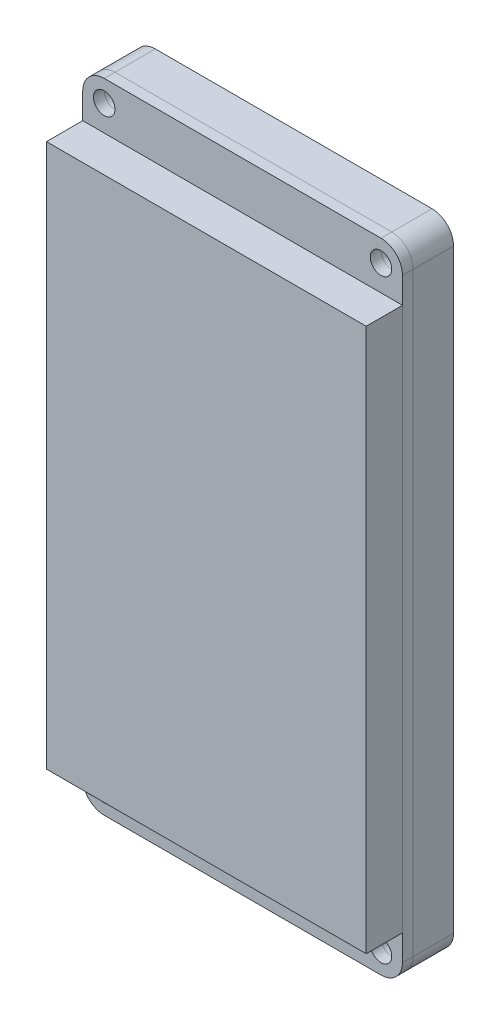
from build123d import *

# Parameters (mm, degrees)
SKETCH1_R           = 1.6
BOSS_EXTRUDE1_DEPTH = 1.6
SKETCH2_W           = 47.6
SKETCH2_H           = 80.9
BOSS_EXTRUDE2_DEPTH = 5.4
SKETCH1_2_R         = 1.6
BOSS_EXTRUDE3_DEPTH = 6
SKETCH3_W           = 15.12
SKETCH3_H           = 7.8
BOSS_EXTRUDE4_DEPTH = 6


with BuildPart() as part:
    # Sketch1 → Boss-Extrude1 (new body)
    with BuildSketch(Plane(origin=(0, 0, 0), x_dir=(0, 1, 0), z_dir=(0, 0, 1))):
        with BuildLine():
            Line((-47.5, 3.881555812), (-47.5, 45.081555812))
            ThreePointArc((-47.5, 45.081555812), (-46.5627417, 47.344297512), (-44.3, 48.281555812))
            Line((-44.3, 48.281555812), (44.3, 48.281555812))
            ThreePointArc((44.3, 48.281555812), (46.5627417, 47.344297512), (47.5, 45.081555812))
            Line((47.5, 45.081555812), (47.5, 3.881555812))
            ThreePointArc((47.5, 3.881555812), (46.5627417, 1.618814112), (44.3, 0.681555812))
            Line((44.3, 0.681555812), (-44.3, 0.681555812))
            ThreePointArc((-44.3, 0.681555812), (-46.5627417, 1.618814112), (-47.5, 3.881555812))
        make_face()
        with Locations((-44.3, 45.081555812)):
            Circle(SKETCH1_R, mode=Mode.SUBTRACT)
        with Locations((-44.3, 3.881555812)):
            Circle(SKETCH1_R, mode=Mode.SUBTRACT)
        with Locations((44.3, 3.881555812)):
            Circle(SKETCH1_R, mode=Mode.SUBTRACT)
        with Locations((44.3, 45.081555812)):
            Circle(SKETCH1_R, mode=Mode.SUBTRACT)
    extrude(amount=BOSS_EXTRUDE1_DEPTH)


with BuildPart() as body_2:
    # Sketch2 → Boss-Extrude2 (new body)
    with BuildSketch(Plane.XY.offset(1.6)):
        with Locations((-24.481555812, 0)):
            Rectangle(SKETCH2_W, SKETCH2_H)
    extrude(amount=BOSS_EXTRUDE2_DEPTH)


with BuildPart() as body_3:
    # Sketch1_2 → Boss-Extrude3 (new body)
    with BuildSketch(Plane(origin=(0, 0, 0), x_dir=(0, 1, 0), z_dir=(0, 0, 1))):
        with BuildLine():
            Line((-47.5, 3.881555812), (-47.5, 45.081555812))
            ThreePointArc((-47.5, 45.081555812), (-46.5627417, 47.344297512), (-44.3, 48.281555812))
            Line((-44.3, 48.281555812), (44.3, 48.281555812))
            ThreePointArc((44.3, 48.281555812), (46.5627417, 47.344297512), (47.5, 45.081555812))
            Line((47.5, 45.081555812), (47.5, 3.881555812))
            ThreePointArc((47.5, 3.881555812), (46.5627417, 1.618814112), (44.3, 0.681555812))
            Line((44.3, 0.681555812), (-44.3, 0.681555812))
            ThreePointArc((-44.3, 0.681555812), (-46.5627417, 1.618814112), (-47.5, 3.881555812))
        make_face()
        with Locations((-44.3, 45.081555812)):
            Circle(SKETCH1_2_R, mode=Mode.SUBTRACT)
        with Locations((-44.3, 3.881555812)):
            Circle(SKETCH1_2_R, mode=Mode.SUBTRACT)
        with Locations((44.3, 3.881555812)):
            Circle(SKETCH1_2_R, mode=Mode.SUBTRACT)
        with Locations((44.3, 45.081555812)):
            Circle(SKETCH1_2_R, mode=Mode.SUBTRACT)
    extrude(amount=-BOSS_EXTRUDE3_DEPTH)


with BuildPart() as body_4:
    # Sketch3 → Boss-Extrude4 (new body)
    with BuildSketch(Plane(origin=(0, 0, 0), x_dir=(1, 0, 0), z_dir=(0, 0, -1))):
        with Locations((-24.481555812, -43.6)):
            Rectangle(SKETCH3_W, SKETCH3_H)
    extrude(amount=BOSS_EXTRUDE4_DEPTH)


solid = Compound([part.part, body_2.part, body_3.part, body_4.part])
